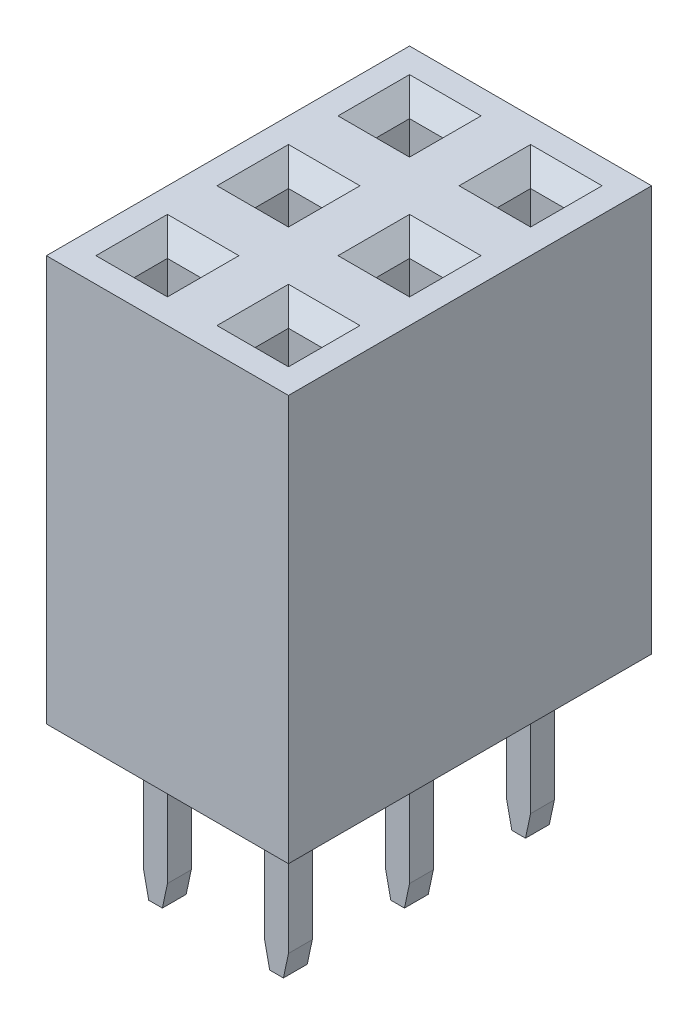
from build123d import *
from OCP.BRepFilletAPI import BRepFilletAPI_MakeChamfer

# Parameters (mm, degrees)
SKETCH_1_W                          = 2.54
SKETCH_1_H                          = 2.54
EXTRUDE_1_DEPTH                     = 8.51
SKETCH_4_W                          = 0.7
SKETCH_4_H                          = 0.7
CUT_EXTRUDE_1_DEPTH                 = 8.21
CHAMFER_3_SIZE                      = 0.4
SKETCH_2_W                          = 0.5
SKETCH_2_H                          = 0.5
EXTRUDE_2_DEPTH                     = 3.15
CHAMFER_2_SIZE                      = 0.5
CHAMFER_2_SIZE2                     = 0.106278281
PATTERN_LINEAR_1_COUNT              = 3
PATTERN_LINEAR_1_PITCH              = 2.54
PATTERN_LINEAR_1_COUNT_DIR2         = 2
PATTERN_LINEAR_1_PITCH_DIR2         = 2.54
CHAMFER_3_OF_PATTERN_LINEAR_1_SIZE  = 0.4
CHAMFER_2_OF_PATTERN_LINEAR_1_SIZE  = 0.5
CHAMFER_2_OF_PATTERN_LINEAR_1_SIZE2 = 0.106278281


with BuildPart() as part:
    # Эскиз1 → Бобышка-Вытянуть1 (new body)
    with BuildSketch(Plane(origin=(0, 0, 0), x_dir=(-1, 0, 0), z_dir=(0, 1, 0))):
        Rectangle(SKETCH_1_W, SKETCH_1_H)
    extrude_1 = extrude(amount=EXTRUDE_1_DEPTH)

    # Эскиз4 → Вырез-Вытянуть1 (cut)
    with BuildSketch(Plane(origin=(0, 8.51, 0), x_dir=(1, 0, 0), z_dir=(0, 1, 0))):
        Rectangle(SKETCH_4_W, SKETCH_4_H)
    cut_extrude_1 = extrude(amount=-CUT_EXTRUDE_1_DEPTH, mode=Mode.SUBTRACT)

    # Фаска3
    chamfer_3_edges = [part.edges().sort_by_distance(p)[0] for p in [
        (-0.35, 8.51, 0),
        (0, 8.51, 0.35),
        (0.35, 8.51, 0),
        (0, 8.51, -0.35),
    ]]
    chamfer(chamfer_3_edges, length=CHAMFER_3_SIZE)

    # Эскиз2 → Бобышка-Вытянуть2 (add)
    with BuildSketch(Plane(origin=(0, 0, 0), x_dir=(-1, 0, 0), z_dir=(0, 1, 0))):
        Rectangle(SKETCH_2_W, SKETCH_2_H)
    extrude_2 = extrude(amount=-EXTRUDE_2_DEPTH)

    # Фаска2: one chamfer whose edges measure the first distance from different faces: ONE call of the kernel's chamfer builder (chamfer() names one face for all edges)
    chamfer_2_edges_1 = [part.edges().sort_by_distance(p)[0] for p in [
        (-0.25, -3.15, 0),
    ]]
    chamfer_2_side_1 = [part.faces().sort_by_distance(p)[0] for p in [
        (-0.25, -1.575, 0),
    ]]
    chamfer_2_edges_2 = [part.edges().sort_by_distance(p)[0] for p in [
        (0.25, -3.15, 0),
    ]]
    chamfer_2_side_2 = [part.faces().sort_by_distance(p)[0] for p in [
        (0.25, -1.575, 0),
    ]]
    chamfer_2 = BRepFilletAPI_MakeChamfer(part.part.solid().wrapped)
    for e in chamfer_2_edges_1:
        chamfer_2.Add(CHAMFER_2_SIZE, CHAMFER_2_SIZE2, e.wrapped, chamfer_2_side_1[0].wrapped)  # the first distance lies on this face
    for e in chamfer_2_edges_2:
        chamfer_2.Add(CHAMFER_2_SIZE, CHAMFER_2_SIZE2, e.wrapped, chamfer_2_side_2[0].wrapped)  # the first distance lies on this face
    add(Compound.cast(chamfer_2.Shape()), mode=Mode.REPLACE)

    # Линейный массив1: Бобышка-Вытянуть1, Вырез-Вытянуть1, Extrude 2 3 × 2
    with Locations(*[(-j * PATTERN_LINEAR_1_PITCH_DIR2, 0, -i * PATTERN_LINEAR_1_PITCH) for i in range(PATTERN_LINEAR_1_COUNT) for j in range(PATTERN_LINEAR_1_COUNT_DIR2) if (i, j) != (0, 0)]):
        add(extrude_1)
        add(cut_extrude_1, mode=Mode.SUBTRACT)
        add(extrude_2)

    # Фаска3 of Линейный массив1
    chamfer_3_of_pattern_linear_1_edges = [part.edges().sort_by_distance(p)[0] for p in [
        (-2.89, 8.51, 0),
        (-2.54, 8.51, 0.35),
        (-2.19, 8.51, 0),
        (-2.54, 8.51, -0.35),
        (-0.35, 8.51, -2.54),
        (0, 8.51, -2.19),
        (0.35, 8.51, -2.54),
        (0, 8.51, -2.89),
        (-2.89, 8.51, -2.54),
        (-2.54, 8.51, -2.19),
        (-2.19, 8.51, -2.54),
        (-2.54, 8.51, -2.89),
        (-0.35, 8.51, -5.08),
        (0, 8.51, -4.73),
        (0.35, 8.51, -5.08),
        (0, 8.51, -5.43),
        (-2.89, 8.51, -5.08),
        (-2.54, 8.51, -4.73),
        (-2.19, 8.51, -5.08),
        (-2.54, 8.51, -5.43),
    ]]
    chamfer(chamfer_3_of_pattern_linear_1_edges, length=CHAMFER_3_OF_PATTERN_LINEAR_1_SIZE)

    # Фаска2 of Линейный массив1: one chamfer whose edges measure the first distance from different faces: ONE call of the kernel's chamfer builder (chamfer() names one face for all edges)
    chamfer_2_of_pattern_linear_1_edges_1 = [part.edges().sort_by_distance(p)[0] for p in [
        (-2.79, -3.15, 0),
    ]]
    chamfer_2_of_pattern_linear_1_side_1 = [part.faces().sort_by_distance(p)[0] for p in [
        (-2.79, -1.575, 0),
    ]]
    chamfer_2_of_pattern_linear_1_edges_2 = [part.edges().sort_by_distance(p)[0] for p in [
        (-2.29, -3.15, 0),
    ]]
    chamfer_2_of_pattern_linear_1_side_2 = [part.faces().sort_by_distance(p)[0] for p in [
        (-2.29, -1.575, 0),
    ]]
    chamfer_2_of_pattern_linear_1_edges_3 = [part.edges().sort_by_distance(p)[0] for p in [
        (-0.25, -3.15, -2.54),
    ]]
    chamfer_2_of_pattern_linear_1_side_3 = [part.faces().sort_by_distance(p)[0] for p in [
        (-0.25, -1.575, -2.54),
    ]]
    chamfer_2_of_pattern_linear_1_edges_4 = [part.edges().sort_by_distance(p)[0] for p in [
        (0.25, -3.15, -2.54),
    ]]
    chamfer_2_of_pattern_linear_1_side_4 = [part.faces().sort_by_distance(p)[0] for p in [
        (0.25, -1.575, -2.54),
    ]]
    chamfer_2_of_pattern_linear_1_edges_5 = [part.edges().sort_by_distance(p)[0] for p in [
        (-2.79, -3.15, -2.54),
    ]]
    chamfer_2_of_pattern_linear_1_side_5 = [part.faces().sort_by_distance(p)[0] for p in [
        (-2.79, -1.575, -2.54),
    ]]
    chamfer_2_of_pattern_linear_1_edges_6 = [part.edges().sort_by_distance(p)[0] for p in [
        (-2.29, -3.15, -2.54),
    ]]
    chamfer_2_of_pattern_linear_1_side_6 = [part.faces().sort_by_distance(p)[0] for p in [
        (-2.29, -1.575, -2.54),
    ]]
    chamfer_2_of_pattern_linear_1_edges_7 = [part.edges().sort_by_distance(p)[0] for p in [
        (-0.25, -3.15, -5.08),
    ]]
    chamfer_2_of_pattern_linear_1_side_7 = [part.faces().sort_by_distance(p)[0] for p in [
        (-0.25, -1.575, -5.08),
    ]]
    chamfer_2_of_pattern_linear_1_edges_8 = [part.edges().sort_by_distance(p)[0] for p in [
        (0.25, -3.15, -5.08),
    ]]
    chamfer_2_of_pattern_linear_1_side_8 = [part.faces().sort_by_distance(p)[0] for p in [
        (0.25, -1.575, -5.08),
    ]]
    chamfer_2_of_pattern_linear_1_edges_9 = [part.edges().sort_by_distance(p)[0] for p in [
        (-2.79, -3.15, -5.08),
    ]]
    chamfer_2_of_pattern_linear_1_side_9 = [part.faces().sort_by_distance(p)[0] for p in [
        (-2.79, -1.575, -5.08),
    ]]
    chamfer_2_of_pattern_linear_1_edges_10 = [part.edges().sort_by_distance(p)[0] for p in [
        (-2.29, -3.15, -5.08),
    ]]
    chamfer_2_of_pattern_linear_1_side_10 = [part.faces().sort_by_distance(p)[0] for p in [
        (-2.29, -1.575, -5.08),
    ]]
    chamfer_2_of_pattern_linear_1 = BRepFilletAPI_MakeChamfer(part.part.solid().wrapped)
    for e in chamfer_2_of_pattern_linear_1_edges_1:
        chamfer_2_of_pattern_linear_1.Add(CHAMFER_2_OF_PATTERN_LINEAR_1_SIZE, CHAMFER_2_OF_PATTERN_LINEAR_1_SIZE2, e.wrapped, chamfer_2_of_pattern_linear_1_side_1[0].wrapped)  # the first distance lies on this face
    for e in chamfer_2_of_pattern_linear_1_edges_2:
        chamfer_2_of_pattern_linear_1.Add(CHAMFER_2_OF_PATTERN_LINEAR_1_SIZE, CHAMFER_2_OF_PATTERN_LINEAR_1_SIZE2, e.wrapped, chamfer_2_of_pattern_linear_1_side_2[0].wrapped)  # the first distance lies on this face
    for e in chamfer_2_of_pattern_linear_1_edges_3:
        chamfer_2_of_pattern_linear_1.Add(CHAMFER_2_OF_PATTERN_LINEAR_1_SIZE, CHAMFER_2_OF_PATTERN_LINEAR_1_SIZE2, e.wrapped, chamfer_2_of_pattern_linear_1_side_3[0].wrapped)  # the first distance lies on this face
    for e in chamfer_2_of_pattern_linear_1_edges_4:
        chamfer_2_of_pattern_linear_1.Add(CHAMFER_2_OF_PATTERN_LINEAR_1_SIZE, CHAMFER_2_OF_PATTERN_LINEAR_1_SIZE2, e.wrapped, chamfer_2_of_pattern_linear_1_side_4[0].wrapped)  # the first distance lies on this face
    for e in chamfer_2_of_pattern_linear_1_edges_5:
        chamfer_2_of_pattern_linear_1.Add(CHAMFER_2_OF_PATTERN_LINEAR_1_SIZE, CHAMFER_2_OF_PATTERN_LINEAR_1_SIZE2, e.wrapped, chamfer_2_of_pattern_linear_1_side_5[0].wrapped)  # the first distance lies on this face
    for e in chamfer_2_of_pattern_linear_1_edges_6:
        chamfer_2_of_pattern_linear_1.Add(CHAMFER_2_OF_PATTERN_LINEAR_1_SIZE, CHAMFER_2_OF_PATTERN_LINEAR_1_SIZE2, e.wrapped, chamfer_2_of_pattern_linear_1_side_6[0].wrapped)  # the first distance lies on this face
    for e in chamfer_2_of_pattern_linear_1_edges_7:
        chamfer_2_of_pattern_linear_1.Add(CHAMFER_2_OF_PATTERN_LINEAR_1_SIZE, CHAMFER_2_OF_PATTERN_LINEAR_1_SIZE2, e.wrapped, chamfer_2_of_pattern_linear_1_side_7[0].wrapped)  # the first distance lies on this face
    for e in chamfer_2_of_pattern_linear_1_edges_8:
        chamfer_2_of_pattern_linear_1.Add(CHAMFER_2_OF_PATTERN_LINEAR_1_SIZE, CHAMFER_2_OF_PATTERN_LINEAR_1_SIZE2, e.wrapped, chamfer_2_of_pattern_linear_1_side_8[0].wrapped)  # the first distance lies on this face
    for e in chamfer_2_of_pattern_linear_1_edges_9:
        chamfer_2_of_pattern_linear_1.Add(CHAMFER_2_OF_PATTERN_LINEAR_1_SIZE, CHAMFER_2_OF_PATTERN_LINEAR_1_SIZE2, e.wrapped, chamfer_2_of_pattern_linear_1_side_9[0].wrapped)  # the first distance lies on this face
    for e in chamfer_2_of_pattern_linear_1_edges_10:
        chamfer_2_of_pattern_linear_1.Add(CHAMFER_2_OF_PATTERN_LINEAR_1_SIZE, CHAMFER_2_OF_PATTERN_LINEAR_1_SIZE2, e.wrapped, chamfer_2_of_pattern_linear_1_side_10[0].wrapped)  # the first distance lies on this face
    add(Compound.cast(chamfer_2_of_pattern_linear_1.Shape()), mode=Mode.REPLACE)


solid = part.part
